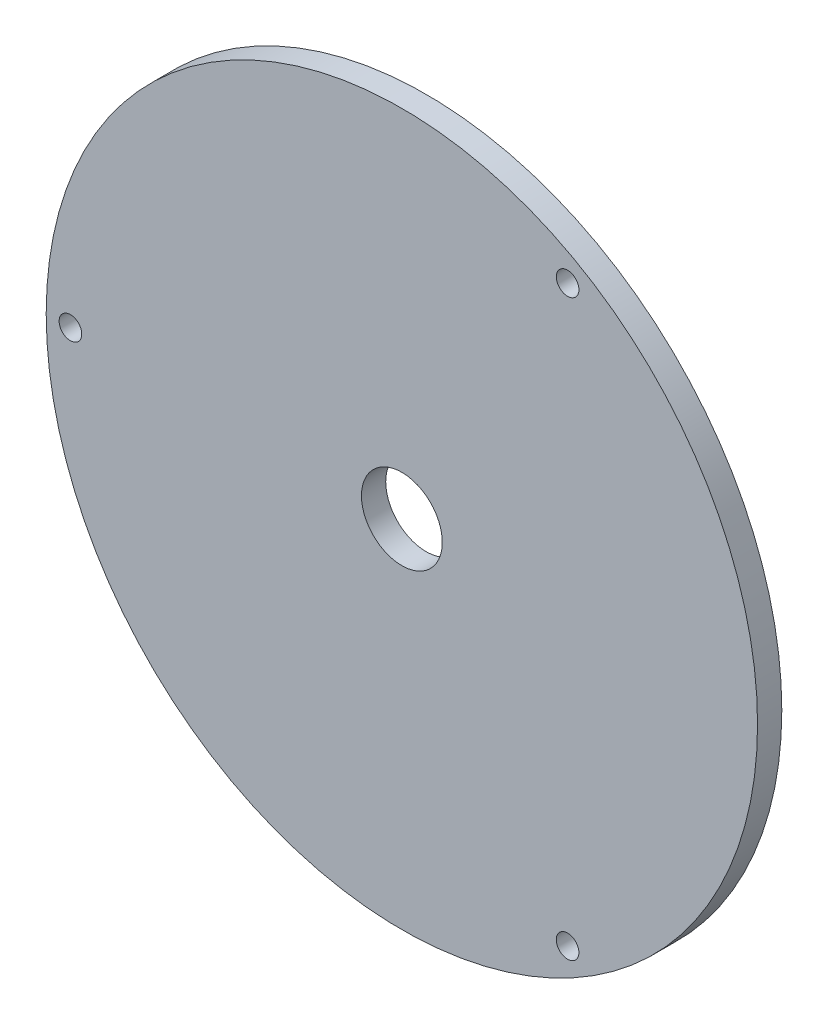
from build123d import *

# Parameters (mm, degrees)
EXTRUDE_1_DEPTH     = 1.5
SKETCH_3_R          = 22
EXTRUDE_2_DEPTH     = 1.5
SKETCH_4_R          = 35.070526428
CUT_EXTRUDE_1_DEPTH = 1.5
SKETCH_5_R          = 0.7
CUT_EXTRUDE_2_DEPTH = 1.5
SKETCH_6_R          = 2.5
CUT_EXTRUDE_3_DEPTH = 1.5


with BuildPart() as part:
    # 草图2 → 凸台-拉伸1 (new body)
    with BuildSketch(Plane.XY):
        with BuildLine():
            Line((-6, -20.3), (6, -20.3))
            Line((6, -20.3), (7.479773249, -16.152182272))
            ThreePointArc((7.479773249, -16.152182272), (0, 17.8), (-7.479773249, -16.152182272))
            Line((-7.479773249, -16.152182272), (-6, -20.3))
        make_face()
    extrude(amount=EXTRUDE_1_DEPTH)

    # 草图3 → 凸台-拉伸2 (add)
    with BuildSketch(Plane.XY.offset(1.5)):
        Circle(SKETCH_3_R)
    extrude(amount=EXTRUDE_2_DEPTH)

    # 草图4 → 切除-拉伸1 (cut)
    with BuildSketch(Plane(origin=(0, 0, 0), x_dir=(-1, 0, 0), z_dir=(0, 0, -1))):
        Circle(SKETCH_4_R)
    extrude(amount=-CUT_EXTRUDE_1_DEPTH, mode=Mode.SUBTRACT)

    # 草图5 → 切除-拉伸2 (cut)
    with BuildSketch(Plane(origin=(0, 0, 1.5), x_dir=(-1, 0, 0), z_dir=(0, 0, -1))):
        with Locations((20.5, 0)):
            Circle(SKETCH_5_R)
        with Locations((-10.25, -17.753520778)):
            Circle(SKETCH_5_R)
        with Locations((-10.25, 17.753520778)):
            Circle(SKETCH_5_R)
    extrude(amount=-CUT_EXTRUDE_2_DEPTH, mode=Mode.SUBTRACT)

    # 草图6 → 切除-拉伸3 (cut)
    with BuildSketch(Plane(origin=(0, 0, 1.5), x_dir=(-1, 0, 0), z_dir=(0, 0, -1))):
        Circle(SKETCH_6_R)
    extrude(amount=-CUT_EXTRUDE_3_DEPTH, mode=Mode.SUBTRACT)


solid = part.part
